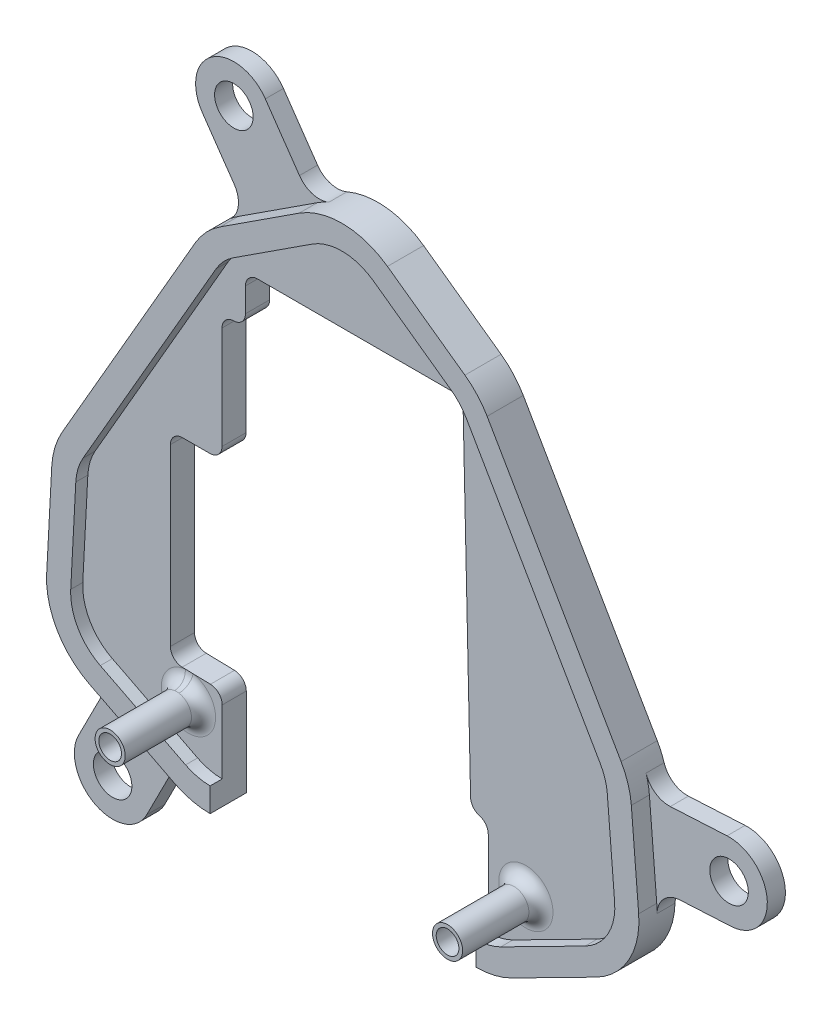
from build123d import *

# Parameters (mm, degrees)
SKETCH2_R             = 0.940847183
BOSS_EXTRUDE1_DEPTH   = 2
SKETCH2_R_2           = 1.25
BOSS_EXTRUDE1_2_DEPTH = 2
BOSS_EXTRUDE3_DEPTH   = 3
SKETCH2_7_R           = 1.25
SKETCH2_7_R_2         = 0.940847183
BOSS_EXTRUDE4_DEPTH   = 8.5
SKETCH3_R             = 1.6
BOSS_EXTRUDE5_DEPTH   = 1.5
FILLET3_R             = 1
FILLET4_R             = 1
FILLET5_R             = 1
SKETCH4_W             = 22.082114238
SKETCH4_H             = 4.26025432
CUT_EXTRUDE1_DEPTH    = 10
FILLET6_R             = 1
FILLET7_R             = 1


with BuildPart() as part:
    # Sketch2 → Boss-Extrude1 (new body)
    with BuildSketch(Plane.XY.offset(5)):
        with Locations((45.192420188, 1.674673151)):
            Circle(SKETCH2_R)
    extrude(amount=BOSS_EXTRUDE1_DEPTH)


with BuildPart() as body_2:
    # Sketch2 → Boss-Extrude1 2 (new body)
    with BuildSketch(Plane.XY.offset(5)):
        with BuildLine():
            Line((41.133082748, 37.634349985), (34.706148145, 42.236237142))
            ThreePointArc((34.706148145, 42.236237142), (31.067550303, 43.449692764), (27.378275076, 42.400351494))
            Line((27.378275076, 42.400351494), (20.830773346, 38.142250332))
            ThreePointArc((20.830773346, 38.142250332), (19.658086914, 37.165968028), (18.745312064, 35.94319958))
            Line((18.745312064, 35.94319958), (7.704226172, 16.81947026))
            ThreePointArc((7.704226172, 16.81947026), (7.101694806, 15.417636125), (6.842562909, 13.91396274))
            Line((6.842562909, 13.91396274), (6.421786289, 5.985399395))
            ThreePointArc((6.421786289, 5.985399395), (7.283504465, 2.390948015), (9.965555118, -0.152522691))
            Line((9.965555118, -0.152522691), (17.042257133, -3.752468769))
            ThreePointArc((17.042257133, -3.752468769), (18.474071457, -4.279870659), (19.989385244, -4.458949249))
            Line((19.989385244, -4.458949249), (42.071499482, -4.458949249))
            ThreePointArc((42.071499482, -4.458949249), (43.586809148, -4.279873865), (45.018620578, -3.752477043))
            Line((45.018620578, -3.752477043), (52.023196139, -0.18925451))
            ThreePointArc((52.023196139, -0.18925451), (54.750476182, 2.433850072), (55.55467988, 6.131415554))
            Line((55.55467988, 6.131415554), (54.945383885, 13.619853326))
            ThreePointArc((54.945383885, 13.619853326), (54.671858346, 15.028435929), (54.095948871, 16.342684554))
            Line((54.095948871, 16.342684554), (42.978078812, 35.599415021))
            ThreePointArc((42.978078812, 35.599415021), (42.164300135, 36.715454096), (41.133082748, 37.634349985))
        make_face()
        with Locations((45.192420188, 1.674673151)):
            Circle(SKETCH2_R_2, mode=Mode.SUBTRACT)
        Polygon((21.92114362, 34.943199877), (39.968717021, 34.943199877), (40.676589536, 3.339551379), (15.692425848, 3.937560139), (15.692425848, 20.422570873), (19.971987097, 20.422570873), (19.971987097, 30.940834749), (21.92114362, 30.940834749), align=None, mode=Mode.SUBTRACT)
    extrude(amount=BOSS_EXTRUDE1_2_DEPTH)

    # Sketch2_4 → Boss-Extrude3 (add)
    with BuildSketch(Plane.XY.offset(5)):
        with BuildLine():
            Line((41.133082748, 37.634349985), (34.706148145, 42.236237142))
            ThreePointArc((34.706148145, 42.236237142), (31.067550303, 43.449692764), (27.378275076, 42.400351494))
            Line((27.378275076, 42.400351494), (20.830773346, 38.142250332))
            ThreePointArc((20.830773346, 38.142250332), (19.658086914, 37.165968028), (18.745312064, 35.94319958))
            Line((18.745312064, 35.94319958), (7.704226172, 16.81947026))
            ThreePointArc((7.704226172, 16.81947026), (7.101694806, 15.417636125), (6.842562909, 13.91396274))
            Line((6.842562909, 13.91396274), (6.421786289, 5.985399395))
            ThreePointArc((6.421786289, 5.985399395), (7.283504465, 2.390948015), (9.965555118, -0.152522691))
            Line((9.965555118, -0.152522691), (17.042257133, -3.752468769))
            ThreePointArc((17.042257133, -3.752468769), (18.474071457, -4.279870659), (19.989385244, -4.458949249))
            Line((19.989385244, -4.458949249), (42.071499482, -4.458949249))
            ThreePointArc((42.071499482, -4.458949249), (43.586809148, -4.279873865), (45.018620578, -3.752477043))
            Line((45.018620578, -3.752477043), (52.023196139, -0.18925451))
            ThreePointArc((52.023196139, -0.18925451), (54.750476182, 2.433850072), (55.55467988, 6.131415554))
            Line((55.55467988, 6.131415554), (54.945383885, 13.619853326))
            ThreePointArc((54.945383885, 13.619853326), (54.671858346, 15.028435929), (54.095948871, 16.342684554))
            Line((54.095948871, 16.342684554), (42.978078812, 35.599415021))
            ThreePointArc((42.978078812, 35.599415021), (42.164300135, 36.715454096), (41.133082748, 37.634349985))
        make_face()
        with BuildLine():
            Line((42.071514619, -2.458949249), (19.989371788, -2.458949249))
            ThreePointArc((19.989371788, -2.458949249), (18.940310927, -2.334974581), (17.949056442, -1.969854112))
            Line((17.949056442, -1.969854112), (10.872362442, 1.630087888))
            ThreePointArc((10.872362442, 1.630087888), (9.015554367, 3.390949582), (8.41897619, 5.8794159))
            Line((8.41897619, 5.8794159), (8.839752837, 13.807979751))
            ThreePointArc((8.839752837, 13.807979751), (9.019149806, 14.848983048), (9.436284279, 15.819482904))
            Line((9.436284279, 15.819482904), (20.477363044, 34.943199877))
            ThreePointArc((20.477363044, 34.943199877), (21.109284015, 35.789731503), (21.92114362, 36.465618987))
            Line((21.92114362, 36.465618987), (28.468652286, 40.72372466))
            ThreePointArc((28.468652286, 40.72372466), (31.022767484, 41.450194202), (33.54179906, 40.610109469))
            Line((33.54179906, 40.610109469), (39.968717021, 36.008234228))
            ThreePointArc((39.968717021, 36.008234228), (40.682635911, 35.37207361), (41.24601974, 34.599429336))
            Line((41.24601974, 34.599429336), (52.363900573, 15.342680208))
            ThreePointArc((52.363900573, 15.342680208), (52.762607381, 14.432817969), (52.951972413, 13.457647575))
            Line((52.951972413, 13.457647575), (53.561268099, 5.969213602))
            ThreePointArc((53.561268099, 5.969213602), (53.004512325, 3.409355177), (51.116390771, 1.593357064))
            Line((51.116390771, 1.593357064), (44.111826917, -1.969859513))
            ThreePointArc((44.111826917, -1.969859513), (43.120573578, -2.334976851), (42.071514619, -2.458949249))
        make_face(mode=Mode.SUBTRACT)
    extrude(amount=BOSS_EXTRUDE3_DEPTH)

    # Sketch2_7 → Boss-Extrude4 (add)
    with BuildSketch(Plane.XY.offset(5)):
        with Locations((45.192420188, 1.674673151)):
            Circle(SKETCH2_7_R)
        with Locations((45.192420188, 1.674673151)):
            Circle(SKETCH2_7_R_2, mode=Mode.SUBTRACT)
        with Locations((17.192425388, 1.674673151)):
            Circle(SKETCH2_7_R)
        with Locations((17.192425388, 1.674673151)):
            Circle(SKETCH2_7_R_2, mode=Mode.SUBTRACT)
    extrude(amount=BOSS_EXTRUDE4_DEPTH)

    # Sketch3 → Boss-Extrude5 (add)
    with BuildSketch(Plane(origin=(0, 0, 5), x_dir=(-1, 0, 0), z_dir=(0, 0, -1))):
        with BuildLine():
            Line((-57.465912559, 7.334344298), (-61.7249195, 7.560353667))
            ThreePointArc((-61.7249195, 7.560353667), (-64.727209986, 10.899141147), (-61.388422506, 13.901431633))
            Line((-61.388422506, 13.901431633), (-56.679353565, 13.651539178))
            ThreePointArc((-56.679353565, 13.651539178), (-55.433923512, 14.005056034), (-54.665941639, 15.047300739))
            Line((-54.665941639, 15.047300739), (-55.572883446, 5.399998251))
            ThreePointArc((-55.572883446, 5.399998251), (-56.142498996, 6.736019854), (-57.465912559, 7.334344298))
        make_face()
        with Locations((-61.556671003, 10.73089265)):
            Circle(SKETCH3_R, mode=Mode.SUBTRACT)
        with BuildLine():
            Line((-17.846979662, 44.100626478), (-20.486080778, 40.282409595))
            ThreePointArc((-20.486080778, 40.282409595), (-20.824333172, 38.888857435), (-20.142867401, 37.627109954))
            Line((-20.142867401, 37.627109954), (-28.341017566, 42.916928771))
            ThreePointArc((-28.341017566, 42.916928771), (-26.996383012, 42.829749498), (-25.901618076, 43.615327019))
            Line((-25.901618076, 43.615327019), (-23.070638788, 47.711150724))
            ThreePointArc((-23.070638788, 47.711150724), (-18.653547102, 48.517718164), (-17.846979662, 44.100626478))
        make_face()
        with Locations((-20.458809225, 45.905888601)):
            Circle(SKETCH3_R, mode=Mode.SUBTRACT)
        with BuildLine():
            Line((-13.224518296, -8.670350201), (-15.108259251, -4.967291533))
            ThreePointArc((-15.108259251, -4.967291533), (-16.179685102, -4.004819306), (-17.619913769, -4.011713354))
            Line((-17.619913769, -4.011713354), (-8.938003872, 0.497808514))
            ThreePointArc((-8.938003872, 0.497808514), (-9.666330862, -0.646021526), (-9.497643296, -1.991514696))
            Line((-9.497643296, -1.991514696), (-7.564735193, -5.791226163))
            ThreePointArc((-7.564735193, -5.791226163), (-8.955064726, -10.060679733), (-13.224518296, -8.670350201))
        make_face()
        with Locations((-10.394626745, -7.230788182)):
            Circle(SKETCH3_R, mode=Mode.SUBTRACT)
    extrude(amount=-BOSS_EXTRUDE5_DEPTH)

    # Fillet3
    fillet3_edges = [body_2.edges().sort_by_distance(p)[0] for p in [
        (15.942425388, 1.674673151, 7),
        (43.942420188, 1.674673151, 7),
    ]]
    fillet(fillet3_edges, radius=FILLET3_R)

    # Fillet4
    fillet4_edges = [body_2.edges().sort_by_distance(p)[0] for p in [
        (19.971987097, 20.422570873, 6),
        (15.692425848, 20.422570873, 6),
        (15.692425848, 3.937560139, 6),
        (40.676589536, 3.339551379, 6),
        (39.968717021, 34.943199877, 6),
        (21.92114362, 34.943199877, 6),
        (21.92114362, 30.940834749, 6),
    ]]
    fillet(fillet4_edges, radius=FILLET4_R)

    # Fillet5
    fillet5_edges = [body_2.edges().sort_by_distance(p)[0] for p in [
        (19.971987097, 30.940834749, 6),
    ]]
    fillet(fillet5_edges, radius=FILLET5_R)

    # Sketch4 → Cut-Extrude1 (cut)
    with BuildSketch(Plane.XZ.offset(4.458949249)):
        with Locations((31.030442363, 5.86987284)):
            Rectangle(SKETCH4_W, SKETCH4_H)
    extrude(amount=-CUT_EXTRUDE1_DEPTH, mode=Mode.SUBTRACT)

    # Fillet6
    fillet6_edges = [body_2.edges().sort_by_distance(p)[0] for p in [
        (19.989385244, 3.834710214, 6),
        (40.627279379, 5.541050751, 6),
    ]]
    fillet(fillet6_edges, radius=FILLET6_R)

    # Fillet7
    fillet7_edges = [body_2.edges().sort_by_distance(p)[0] for p in [
        (42.071499482, 5.541050751, 6),
    ]]
    fillet(fillet7_edges, radius=FILLET7_R)


with BuildPart() as part_1:
    add(part.part)

    # Combine1: union body 2
    add(body_2.part)


solid = part_1.part
